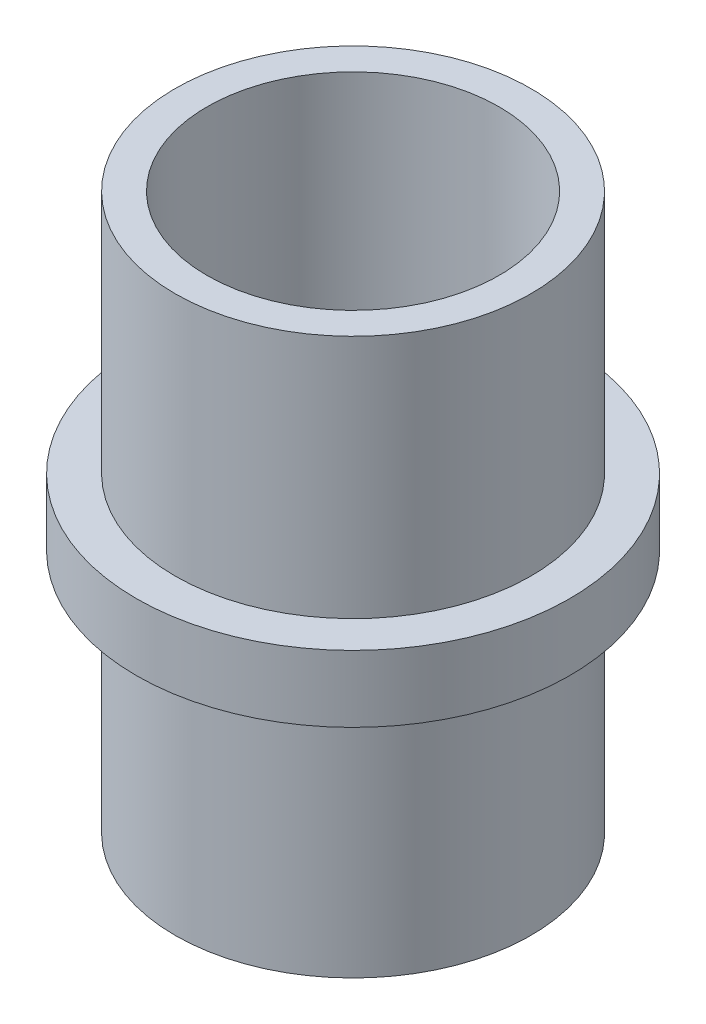
from build123d import *

# Parameters (mm, degrees)
SKETCH1_R           = 16
SKETCH1_R_2         = 13.1445
BOSS_EXTRUDE1_DEPTH = 25
SKETCH2_R           = 19.5
SKETCH2_R_2         = 16
BOSS_EXTRUDE2_DEPTH = 3
CUT_EXTRUDE1_REACH  = 21.5
SKETCH3_R           = 2


with BuildPart() as part:
    # Sketch1 → Boss-Extrude1 (new body, symmetric)
    with BuildSketch(Plane(origin=(0, 0, 0), x_dir=(1, 0, 0), z_dir=(0, 1, 0))):
        Circle(SKETCH1_R)
        Circle(SKETCH1_R_2, mode=Mode.SUBTRACT)
    extrude(amount=BOSS_EXTRUDE1_DEPTH, both=True)

    # Sketch2 → Boss-Extrude2 (add, symmetric)
    with BuildSketch(Plane(origin=(0, 0, 0), x_dir=(1, 0, 0), z_dir=(0, 1, 0))):
        Circle(SKETCH2_R)
        Circle(SKETCH2_R_2, mode=Mode.SUBTRACT)
    extrude(amount=BOSS_EXTRUDE2_DEPTH, both=True)

    # Sketch3 → Cut-Extrude1 (cut, up to next)
    with BuildSketch(Plane.XY, mode=Mode.PRIVATE) as cut_extrude1_sk1:
        Circle(SKETCH3_R)
    cut_extrude1_tool1 = extrude(cut_extrude1_sk1.sketch, amount=-CUT_EXTRUDE1_REACH, mode=Mode.PRIVATE) & part.part
    add(cut_extrude1_tool1.solids().sort_by_distance((0, 0, 0))[0], mode=Mode.SUBTRACT)


solid = part.part
